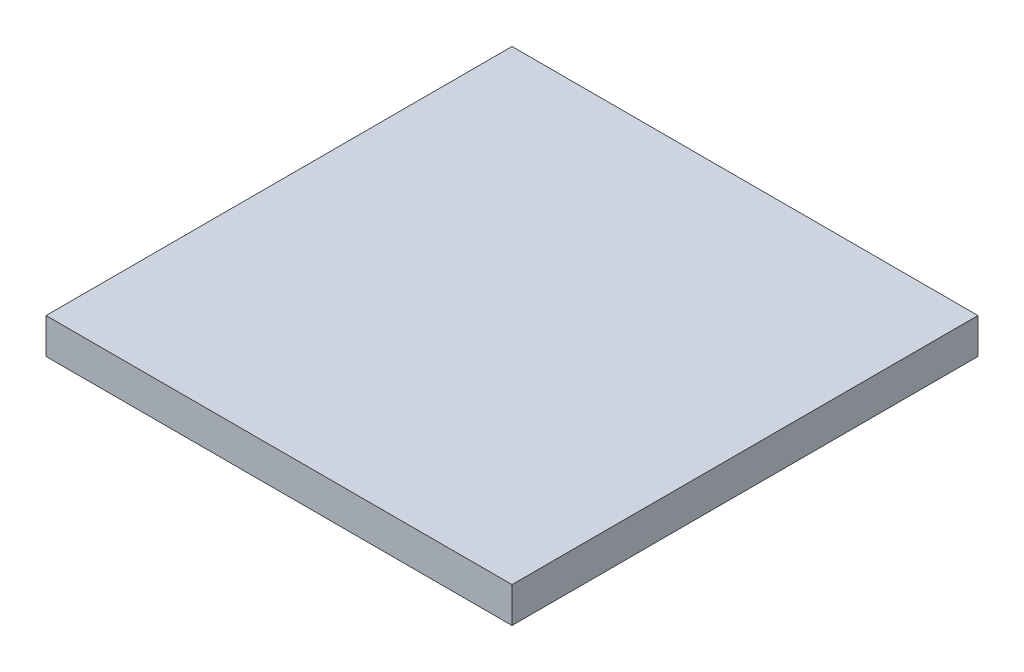
from build123d import *

# Parameters (mm, degrees)
SKETCH2_W           = 131.448329588
SKETCH2_H           = 131.45
BOSS_EXTRUDE2_DEPTH = 10


with BuildPart() as part:
    # Sketch2 → Boss-Extrude2 (new body)
    with BuildSketch(Plane(origin=(0, 0, 0), x_dir=(1, 0, 0), z_dir=(0, 1, 0))):
        with Locations((-65.724164794, 73.487696629)):
            Rectangle(SKETCH2_W, SKETCH2_H)
    extrude(amount=BOSS_EXTRUDE2_DEPTH)


solid = part.part
